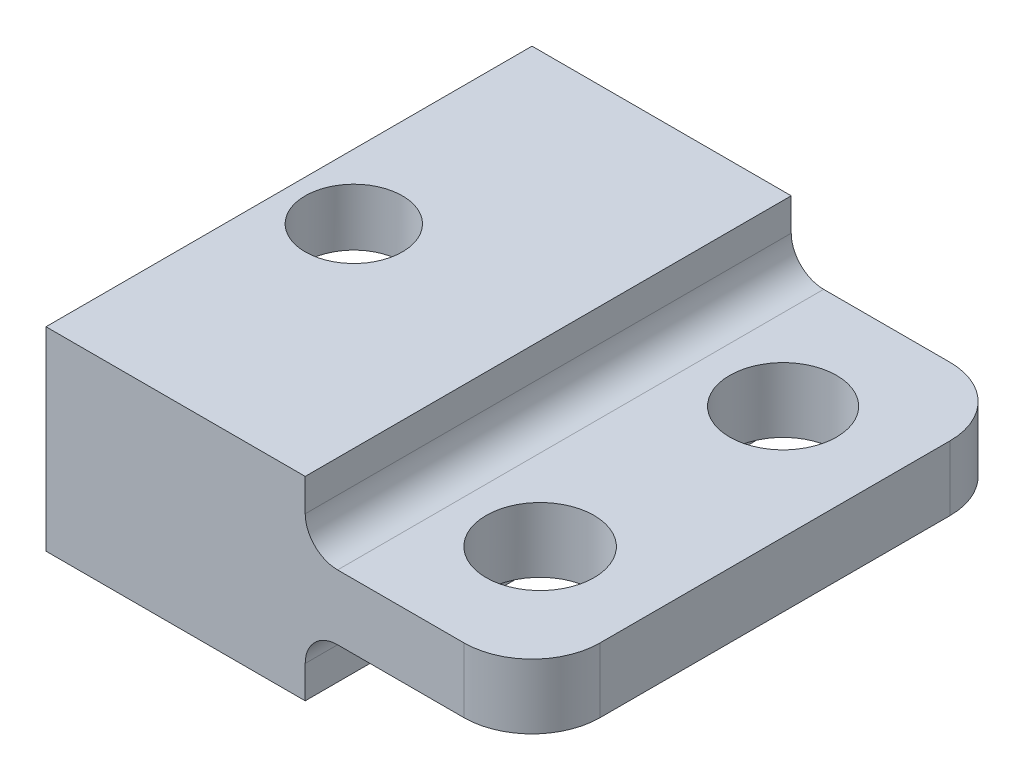
from build123d import *

# Parameters (mm, degrees)
SKETCH1_W           = 7
SKETCH1_H           = 15
SKETCH1_W_2         = 8
BOSS_EXTRUDE1_DEPTH = 2
SKETCH2_W           = 8
SKETCH2_H           = 15
BOSS_EXTRUDE2_DEPTH = 2
SKETCH3_W           = 8
SKETCH3_H           = 15
BOSS_EXTRUDE4_DEPTH = 2
SKETCH4_R           = 1.665
SKETCH4_R_2         = 1.65
CUT_EXTRUDE1_DEPTH  = 9
FILLET1_R           = 2.1
FILLET2_R           = 2.1
SKETCH5_W           = 12
SKETCH5_H           = 3
CUT_EXTRUDE2_DEPTH  = 3.8
SKETCH6_R           = 1.5
CUT_EXTRUDE3_DEPTH  = 17.2
FILLET3_R           = 1
FILLET4_R           = 1
SKETCH7_W           = 12
SKETCH7_H           = 3
CUT_EXTRUDE4_DEPTH  = 0.2


with BuildPart() as part:
    # Sketch1 → Boss-Extrude1 (new body)
    with BuildSketch(Plane(origin=(0, 0, 0), x_dir=(1, 0, 0), z_dir=(0, 1, 0))):
        with Locations((-3.5, 7.5)):
            Rectangle(SKETCH1_W, SKETCH1_H)
        with Locations((4, 7.5)):
            Rectangle(SKETCH1_W_2, SKETCH1_H)
    extrude(amount=BOSS_EXTRUDE1_DEPTH)

    # Sketch2 → Boss-Extrude2 (add)
    with BuildSketch(Plane.XZ):
        with Locations((-3, -7.5)):
            Rectangle(SKETCH2_W, SKETCH2_H)
    extrude(amount=BOSS_EXTRUDE2_DEPTH)

    # Sketch3 → Boss-Extrude4 (add)
    with BuildSketch(Plane(origin=(0, 2, 0), x_dir=(1, 0, 0), z_dir=(0, 1, 0))):
        with Locations((-3, 7.5)):
            Rectangle(SKETCH3_W, SKETCH3_H)
    extrude(amount=BOSS_EXTRUDE4_DEPTH)

    # Sketch4 → Cut-Extrude1 (cut)
    with BuildSketch(Plane(origin=(0, 0, 0), x_dir=(-1, 0, 0), z_dir=(0, -1, 0))):
        with Locations((-4.5, 3.75)):
            Circle(SKETCH4_R)
        with Locations((-4.5, 11.25)):
            Circle(SKETCH4_R_2)
    extrude(amount=-CUT_EXTRUDE1_DEPTH, mode=Mode.SUBTRACT)

    # Fillet1
    fillet1_edges = [part.edges().sort_by_distance(p)[0] for p in [
        (8, 1, 0),
    ]]
    fillet(fillet1_edges, radius=FILLET1_R)

    # Fillet2
    fillet2_edges = [part.edges().sort_by_distance(p)[0] for p in [
        (8, 1, -15),
    ]]
    fillet(fillet2_edges, radius=FILLET2_R)

    # Sketch5 → Cut-Extrude2 (cut)
    with BuildSketch(Plane.ZY.offset(7)):
        with Locations((-7.5, 0.736813471)):
            Rectangle(SKETCH5_W, SKETCH5_H)
    extrude(amount=-CUT_EXTRUDE2_DEPTH, mode=Mode.SUBTRACT)

    # Sketch6 → Cut-Extrude3 (cut)
    with BuildSketch(Plane(origin=(0, 4, 0), x_dir=(1, 0, 0), z_dir=(0, 1, 0))):
        with Locations((-5, 7.5)):
            Circle(SKETCH6_R)
    extrude(amount=-CUT_EXTRUDE3_DEPTH, mode=Mode.SUBTRACT)

    # Fillet3
    fillet3_edges = [part.edges().sort_by_distance(p)[0] for p in [
        (1, 0, -7.5),
    ]]
    fillet(fillet3_edges, radius=FILLET3_R)

    # Fillet4
    fillet4_edges = [part.edges().sort_by_distance(p)[0] for p in [
        (1, 2, -7.5),
    ]]
    fillet(fillet4_edges, radius=FILLET4_R)

    # Sketch7 → Cut-Extrude4 (cut)
    with BuildSketch(Plane.ZY.offset(3.2)):
        with Locations((-7.5, 0.736813471)):
            Rectangle(SKETCH7_W, SKETCH7_H)
    extrude(amount=-CUT_EXTRUDE4_DEPTH, mode=Mode.SUBTRACT)


solid = part.part
